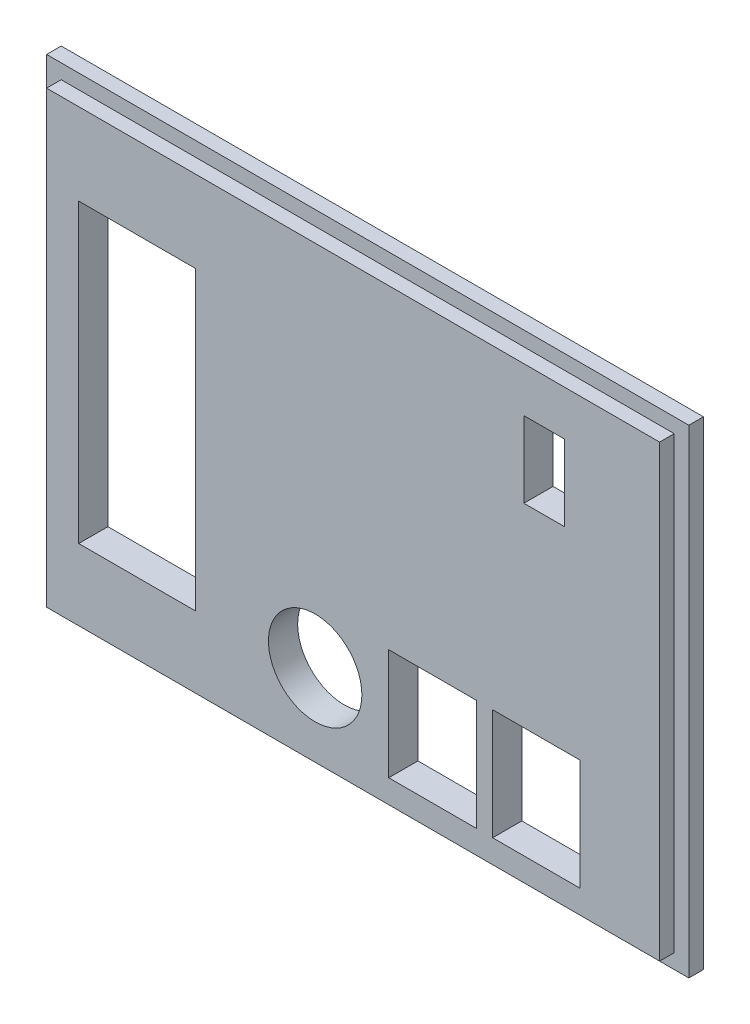
from build123d import *

# Parameters (mm, degrees)
SKETCH2_W           = 110
SKETCH2_H           = 82
BOSS_EXTRUDE1_DEPTH = 5
SKETCH13_W          = 20.02707563
SKETCH13_H          = 50.8
CUT_EXTRUDE12_DEPTH = 5
SKETCH14_W          = 2.498354032
SKETCH14_H          = 82
CUT_EXTRUDE13_DEPTH = 2.5
SKETCH15_W          = 107.501645968
SKETCH15_H          = 2.500122833
CUT_EXTRUDE14_DEPTH = 2.5
SKETCH16_W          = 107.501645968
SKETCH16_H          = 2.501703456
CUT_EXTRUDE15_DEPTH = 2.5
SKETCH18_W          = 2.5
SKETCH18_H          = 76.998173711
CUT_EXTRUDE18_DEPTH = 2.5
SKETCH19_W          = 7.5
SKETCH19_H          = 9.5
CUT_EXTRUDE19_DEPTH = 10
SKETCH20_W          = 7.5
SKETCH20_H          = 9.5
CUT_EXTRUDE20_DEPTH = 10
CUT_EXTRUDE21_DEPTH = 8
SKETCH22_W          = 7
SKETCH22_H          = 13
CUT_EXTRUDE22_DEPTH = 10


with BuildPart() as part:
    # Sketch2 → Boss-Extrude1 (new body)
    with BuildSketch(Plane.XY):
        Rectangle(SKETCH2_W, SKETCH2_H)
    extrude(amount=BOSS_EXTRUDE1_DEPTH)

    # Sketch13 → Cut-Extrude12 (cut)
    with BuildSketch(Plane.XY.offset(5)):
        with Locations((-36.986462185, -0.9)):
            Rectangle(SKETCH13_W, SKETCH13_H)
    extrude(amount=-CUT_EXTRUDE12_DEPTH, mode=Mode.SUBTRACT)

    # Sketch14 → Cut-Extrude13 (cut)
    with BuildSketch(Plane.XY.offset(5)):
        with Locations((-53.750822984, 0)):
            Rectangle(SKETCH14_W, SKETCH14_H)
    extrude(amount=-CUT_EXTRUDE13_DEPTH, mode=Mode.SUBTRACT)

    # Sketch15 → Cut-Extrude14 (cut)
    with BuildSketch(Plane.XY.offset(5)):
        with Locations((1.249177016, -39.749938583)):
            Rectangle(SKETCH15_W, SKETCH15_H)
    extrude(amount=-CUT_EXTRUDE14_DEPTH, mode=Mode.SUBTRACT)

    # Sketch16 → Cut-Extrude15 (cut)
    with BuildSketch(Plane.XY.offset(5)):
        with Locations((1.249177016, 39.749148272)):
            Rectangle(SKETCH16_W, SKETCH16_H)
    extrude(amount=-CUT_EXTRUDE15_DEPTH, mode=Mode.SUBTRACT)

    # Sketch18 → Cut-Extrude18 (cut)
    with BuildSketch(Plane.XY.offset(5)):
        with Locations((53.75, -0.000790311)):
            Rectangle(SKETCH18_W, SKETCH18_H)
    extrude(amount=-CUT_EXTRUDE18_DEPTH, mode=Mode.SUBTRACT)

    # Sketch19 → Cut-Extrude19 (cut)
    with BuildSketch(Plane.XY.offset(5)):
        Polygon((6.1, -34.499877167), (13.6, -34.499877167), (13.6, -24.999877167), (21.1, -24.999877167), (21.1, -15.499877167), (6.1, -15.499877167), align=None)
        with Locations((17.35, -29.749877167)):
            Rectangle(SKETCH19_W, SKETCH19_H)
    extrude(amount=-CUT_EXTRUDE19_DEPTH, mode=Mode.SUBTRACT)

    # Sketch20 → Cut-Extrude20 (cut)
    with BuildSketch(Plane.XY.offset(5)):
        Polygon((31.4, -24.999877167), (38.9, -24.999877167), (38.9, -15.499877167), (23.9, -15.499877167), (23.9, -34.499877167), (31.4, -34.499877167), align=None)
        with Locations((35.15, -29.749877167)):
            Rectangle(SKETCH20_W, SKETCH20_H)
    extrude(amount=-CUT_EXTRUDE20_DEPTH, mode=Mode.SUBTRACT)

    # Sketch21 → Cut-Extrude21 (cut)
    with BuildSketch(Plane.XY.offset(5)):
        with BuildLine():
            ThreePointArc((1.498354032, -24.499877167), (-6.501645968, -16.499877167), (-14.501645968, -24.499877167))
            Line((-14.501645968, -24.499877167), (-6.501645968, -24.499877167))
            Line((-6.501645968, -24.499877167), (-6.501645968, -32.499877167))
            ThreePointArc((-6.501645968, -32.499877167), (-0.844791718, -30.156731417), (1.498354032, -24.499877167))
        make_face()
        with BuildLine():
            Line((-6.501645968, -24.499877167), (-14.501645968, -24.499877167))
            ThreePointArc((-14.501645968, -24.499877167), (-12.158500217, -30.156731417), (-6.501645968, -32.499877167))
            Line((-6.501645968, -32.499877167), (-6.501645968, -24.499877167))
        make_face()
    extrude(amount=-CUT_EXTRUDE21_DEPTH, mode=Mode.SUBTRACT)

    # Sketch22 → Cut-Extrude22 (cut)
    with BuildSketch(Plane.XY.offset(5)):
        with Locations((32.75, 24.298296544)):
            Rectangle(SKETCH22_W, SKETCH22_H)
    extrude(amount=-CUT_EXTRUDE22_DEPTH, mode=Mode.SUBTRACT)


solid = part.part
